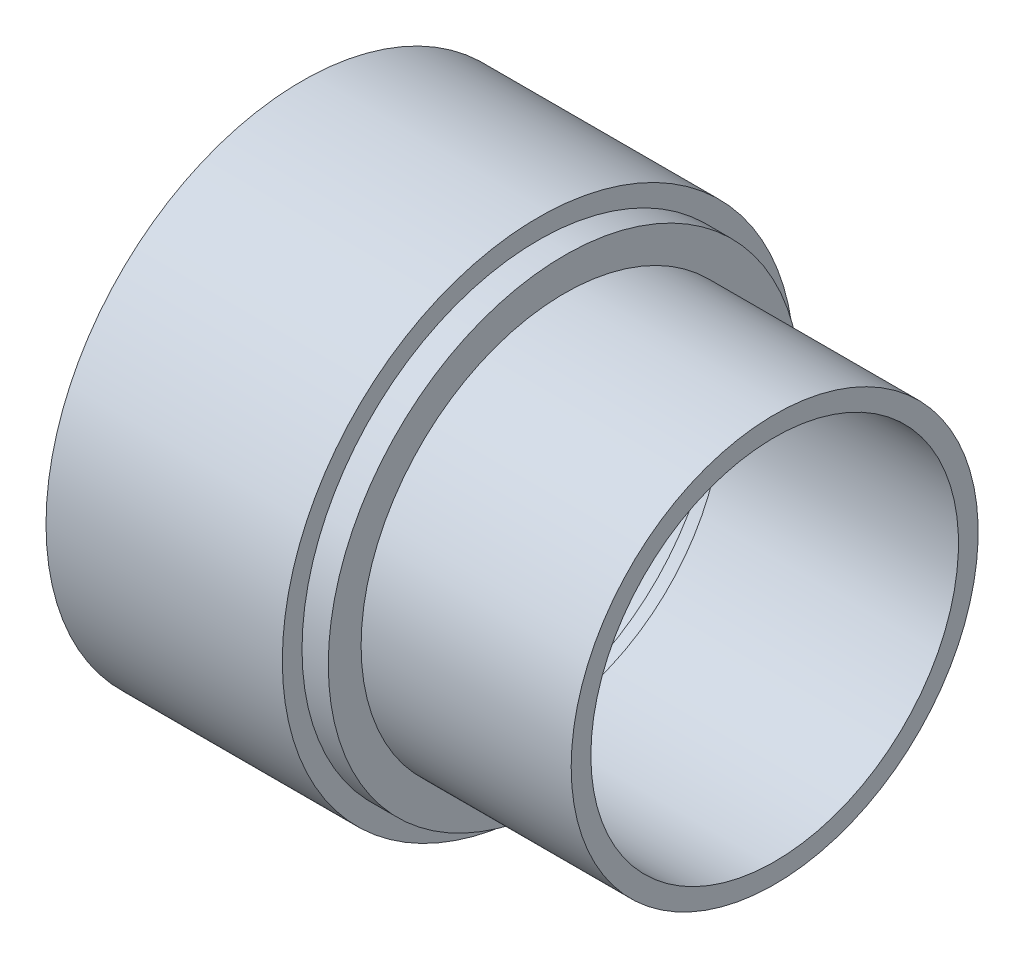
from build123d import *

# Parameters (mm, degrees)
SKETCH1_W = 12.7
SKETCH1_H = 7.9375
SKETCH2_W = 57.15
SKETCH2_H = 4.7625


with BuildPart() as part:
    # Sketch1 → Revolve1 (revolve)
    with BuildSketch(Plane.XY, mode=Mode.PRIVATE) as revolve1_sk:
        with Locations((0, 53.18125)):
            Rectangle(SKETCH1_W, SKETCH1_H)
    revolve(revolve1_sk.sketch.rotate(Axis((0, 0, 0), (1, 0, 0)), 90), axis=Axis((0, 0, 0), (1, 0, 0)))  # turned: the seam where the file's is


with BuildPart() as body_2:
    # Sketch2 → Revolve2 (revolve)
    with BuildSketch(Plane.XY, mode=Mode.PRIVATE) as revolve2_sk:
        with Locations((-28.575, 59.53125)):
            Rectangle(SKETCH2_W, SKETCH2_H)
        with Locations((28.575, 46.83125)):
            Rectangle(SKETCH2_W, SKETCH2_H)
    revolve(revolve2_sk.sketch.rotate(Axis((0, 0, 0), (1, 0, 0)), 90), axis=Axis((0, 0, 0), (1, 0, 0)))  # turned: the seam where the file's is


solid = Compound([part.part, body_2.part])
